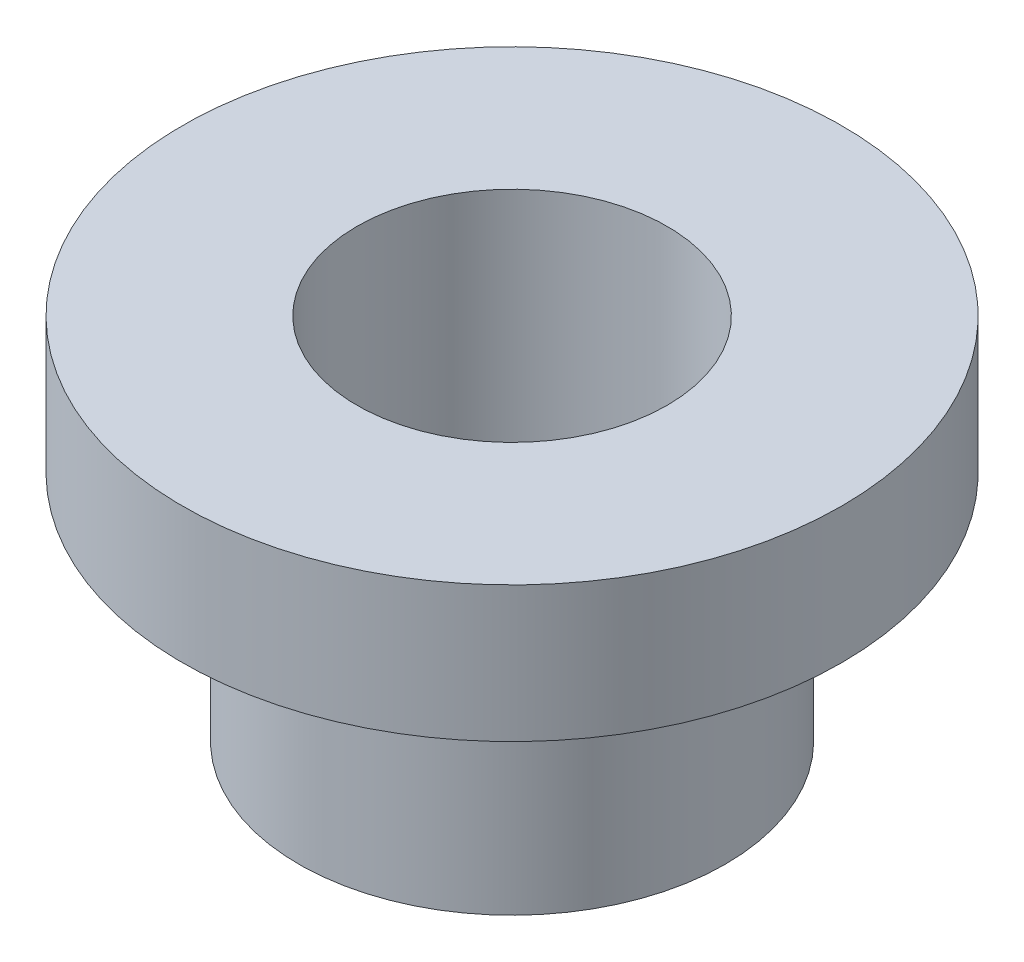
from build123d import *


with BuildPart() as part:
    # Croquis1 → Revolución1 (revolve)
    with BuildSketch(Plane.XY):
        Polygon((-8, 19), (-17, 19), (-17, 12), (-11, 12), (-11, 0), (-8, 0), align=None)
    revolve(axis=Axis((0, 0, 0), (0, 1, 0)))


solid = part.part
